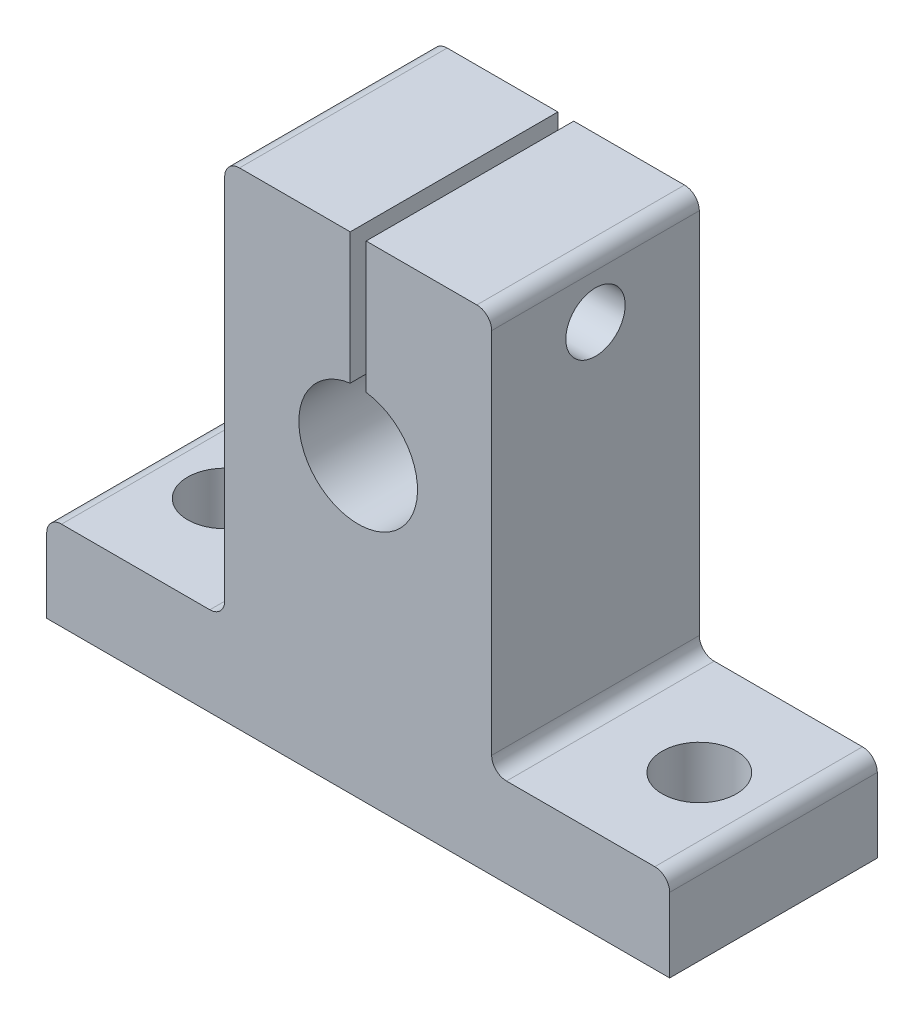
from build123d import *

# Parameters (mm, degrees)
SKETCH_1_R          = 4
EXTRUDE_1_DEPTH     = 14
SKETCH_2_R          = 2.5
CUT_EXTRUDE_1_DEPTH = 14
SKETCH_3_W          = 1.071241762
SKETCH_3_H          = 14
CUT_EXTRUDE_2_DEPTH = 14
SKETCH_4_R          = 2
CUT_EXTRUDE_3_DEPTH = 60
FILLET_1_R          = 1
FILLET_2_R          = 1


with BuildPart() as part:
    # 草图1 → 凸台-拉伸1 (new body)
    with BuildSketch(Plane.XY):
        Polygon((-22.707070707, -12.272727273), (19.292929293, -12.272727273), (19.292929293, -6.272727273), (7.292929293, -6.272727273), (7.292929293, 20.527272727), (0.929292929, 20.527272727), (-10.707070707, 20.527272727), (-10.707070707, -6.272727273), (-22.707070707, -6.272727273), align=None)
        with Locations((-1.707070707, 7.727272727)):
            Circle(SKETCH_1_R, mode=Mode.SUBTRACT)
    extrude(amount=EXTRUDE_1_DEPTH)

    # 草图2 → 切除-拉伸1 (cut)
    with BuildSketch(Plane(origin=(0, -6.272727273, 0), x_dir=(1, 0, 0), z_dir=(0, 1, 0))):
        with Locations((-17.707070707, -7)):
            Circle(SKETCH_2_R)
        with Locations((14.292929293, -7)):
            Circle(SKETCH_2_R)
    extrude(amount=-CUT_EXTRUDE_1_DEPTH, mode=Mode.SUBTRACT)

    # 草图3 → 切除-拉伸2 (cut)
    with BuildSketch(Plane(origin=(0, 20.527272727, 0), x_dir=(1, 0, 0), z_dir=(0, 1, 0))):
        with Locations((-1.707070707, -7)):
            Rectangle(SKETCH_3_W, SKETCH_3_H)
    extrude(amount=-CUT_EXTRUDE_2_DEPTH, mode=Mode.SUBTRACT)

    # 草图4 → 切除-拉伸3 (cut)
    with BuildSketch(Plane(origin=(7.292929293, 0, 0), x_dir=(0, 0, -1), z_dir=(1, 0, 0))):
        with Locations((-7, 16.527272727)):
            Circle(SKETCH_4_R)
    extrude(amount=-CUT_EXTRUDE_3_DEPTH, mode=Mode.SUBTRACT)

    # 圆角1
    fillet_1_edges = [part.edges().sort_by_distance(p)[0] for p in [
        (7.292929293, 20.527272727, 7),
        (19.292929293, -6.272727273, 7),
        (-22.707070707, -6.272727273, 7),
        (-10.707070707, 20.527272727, 7),
    ]]
    fillet(fillet_1_edges, radius=FILLET_1_R)

    # 圆角2
    fillet_2_edges = [part.edges().sort_by_distance(p)[0] for p in [
        (7.292929293, -6.272727273, 7),
        (-10.707070707, -6.272727273, 7),
    ]]
    fillet(fillet_2_edges, radius=FILLET_2_R)


solid = part.part
